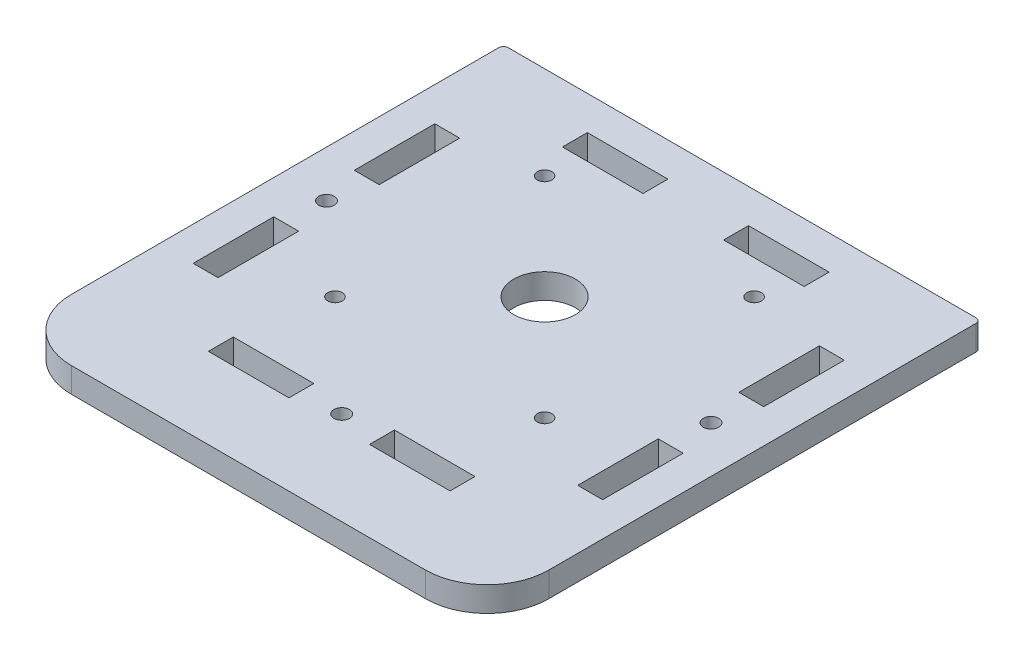
from build123d import *

# Parameters (mm, degrees)
MAIN_DEPTH                     = 5.13
F_3_0_3_DIAMETER_HOLE2_D       = 3
F_3_0_3_DIAMETER_HOLE2_DEPTH   = 5.13
SKETCH4_W                      = 5.13
SKETCH4_H                      = 16.6
TEETH_HOLES_DEPTH              = 5.13
TEETH_HOLES_2_REACH            = 7.13
SKETCH5_W                      = 16.6
SKETCH5_H                      = 5.13
F_1_2_0_5_DIAMETER_HOLE1_D     = 12.7
F_1_2_0_5_DIAMETER_HOLE1_DEPTH = 5.13
M3_CLEARANCE_HOLE2_D           = 3.2
M3_CLEARANCE_HOLE2_DEPTH       = 5.08
M3_CLEARANCE_HOLE2_TIP         = 0.96137699


with BuildPart() as part:
    # Sketch1 → Main (new body)
    with BuildSketch(Plane(origin=(0, 0, 0), x_dir=(1, 0, 0), z_dir=(0, 1, 0))):
        with BuildLine():
            Line((-81.610197541, 55.143891453), (14.749802459, 55.143891453))
            ThreePointArc((14.749802459, 55.143891453), (15.456909241, 54.850998234), (15.749802459, 54.143891453))
            Line((15.749802459, 54.143891453), (15.749802459, -33.877426122))
            ThreePointArc((15.749802459, -33.877426122), (12.03005858, -42.857682243), (3.049802459, -46.577426122))
            Line((3.049802459, -46.577426122), (-69.910197541, -46.577426122))
            ThreePointArc((-69.910197541, -46.577426122), (-78.890453662, -42.857682243), (-82.610197541, -33.877426122))
            Line((-82.610197541, -33.877426122), (-82.610197541, 54.143891453))
            ThreePointArc((-82.610197541, 54.143891453), (-82.317304322, 54.850998234), (-81.610197541, 55.143891453))
        make_face()
    extrude(amount=MAIN_DEPTH)

    # Ø3.0 (3) Diameter Hole2
    with Locations(Plane(origin=(0, 5.13, 0), x_dir=(-1, 0, 0), z_dir=(0, 1, 0))):
        with Locations((55.020197541, -36.023891453), (11.840197541, -36.023891453), (55.020197541, 7.156108547), (11.840197541, 7.156108547)):
            Hole(F_3_0_3_DIAMETER_HOLE2_D / 2, depth=F_3_0_3_DIAMETER_HOLE2_DEPTH)

    # Sketch4 → Teeth holes (cut)
    with BuildSketch(Plane(origin=(0, 5.13, 0), x_dir=(1, 0, 0), z_dir=(0, 1, 0))):
        with Locations((-73.045197541, 25.708891453)):
            Rectangle(SKETCH4_W, SKETCH4_H)
        with Locations((6.184802459, 25.708891453)):
            Rectangle(SKETCH4_W, SKETCH4_H)
        with Locations((-73.045197541, -7.491108547)):
            Rectangle(SKETCH4_W, SKETCH4_H)
        with Locations((6.184802459, -7.491108547)):
            Rectangle(SKETCH4_W, SKETCH4_H)
    extrude(amount=-TEETH_HOLES_DEPTH, mode=Mode.SUBTRACT)

    # Sketch5 → Teeth holes 2 (cut, up to next)
    with BuildSketch(Plane(origin=(0, 5.13, 0), x_dir=(1, 0, 0), z_dir=(0, 1, 0)), mode=Mode.PRIVATE) as teeth_holes_2_sk1:
        with Locations((-50.030197541, 45.578891453)):
            Rectangle(SKETCH5_W, SKETCH5_H)
    teeth_holes_2_tool1 = extrude(teeth_holes_2_sk1.sketch, amount=-TEETH_HOLES_2_REACH, mode=Mode.PRIVATE) & part.part
    add(teeth_holes_2_tool1.solids().sort_by_distance((-50.030198, 5.13, -45.578891))[0], mode=Mode.SUBTRACT)
    # Sketch5 → Teeth holes 2 (cut, up to next)
    with BuildSketch(Plane(origin=(0, 5.13, 0), x_dir=(1, 0, 0), z_dir=(0, 1, 0)), mode=Mode.PRIVATE) as teeth_holes_2_sk2:
        with Locations((-16.830197541, 45.578891453)):
            Rectangle(SKETCH5_W, SKETCH5_H)
    teeth_holes_2_tool2 = extrude(teeth_holes_2_sk2.sketch, amount=-TEETH_HOLES_2_REACH, mode=Mode.PRIVATE) & part.part
    add(teeth_holes_2_tool2.solids().sort_by_distance((-16.830198, 5.13, -45.578891))[0], mode=Mode.SUBTRACT)
    # Sketch5 → Teeth holes 2 (cut, up to next)
    with BuildSketch(Plane(origin=(0, 5.13, 0), x_dir=(1, 0, 0), z_dir=(0, 1, 0)), mode=Mode.PRIVATE) as teeth_holes_2_sk3:
        with Locations((-50.030197541, -27.361108547)):
            Rectangle(SKETCH5_W, SKETCH5_H)
    teeth_holes_2_tool3 = extrude(teeth_holes_2_sk3.sketch, amount=-TEETH_HOLES_2_REACH, mode=Mode.PRIVATE) & part.part
    add(teeth_holes_2_tool3.solids().sort_by_distance((-50.030198, 5.13, 27.361109))[0], mode=Mode.SUBTRACT)
    # Sketch5 → Teeth holes 2 (cut, up to next)
    with BuildSketch(Plane(origin=(0, 5.13, 0), x_dir=(1, 0, 0), z_dir=(0, 1, 0)), mode=Mode.PRIVATE) as teeth_holes_2_sk4:
        with Locations((-16.830197541, -27.361108547)):
            Rectangle(SKETCH5_W, SKETCH5_H)
    teeth_holes_2_tool4 = extrude(teeth_holes_2_sk4.sketch, amount=-TEETH_HOLES_2_REACH, mode=Mode.PRIVATE) & part.part
    add(teeth_holes_2_tool4.solids().sort_by_distance((-16.830198, 5.13, 27.361109))[0], mode=Mode.SUBTRACT)

    # 1/2 (0.5) Diameter Hole1
    with Locations(Plane(origin=(0, 5.13, 0), x_dir=(-1, 0, 0), z_dir=(0, 1, 0))):
        with Locations((33.430197541, -14.433891453)):
            Hole(F_1_2_0_5_DIAMETER_HOLE1_D / 2, depth=F_1_2_0_5_DIAMETER_HOLE1_DEPTH)

    # M3 Clearance Hole2
    with Locations(Plane(origin=(0, 5.13, 0), x_dir=(-1, 0, 0), z_dir=(0, 1, 0))):
        with Locations((73.045197541, -9.108891453), (-6.184802459, -9.108891453), (33.430197541, 27.361108547)):
            Hole(M3_CLEARANCE_HOLE2_D / 2, depth=M3_CLEARANCE_HOLE2_DEPTH)
            with Locations((0, 0, -(M3_CLEARANCE_HOLE2_DEPTH + M3_CLEARANCE_HOLE2_TIP / 2))):  # 118° drill point
                Cone(0, M3_CLEARANCE_HOLE2_D / 2, M3_CLEARANCE_HOLE2_TIP, mode=Mode.SUBTRACT)


solid = part.part
